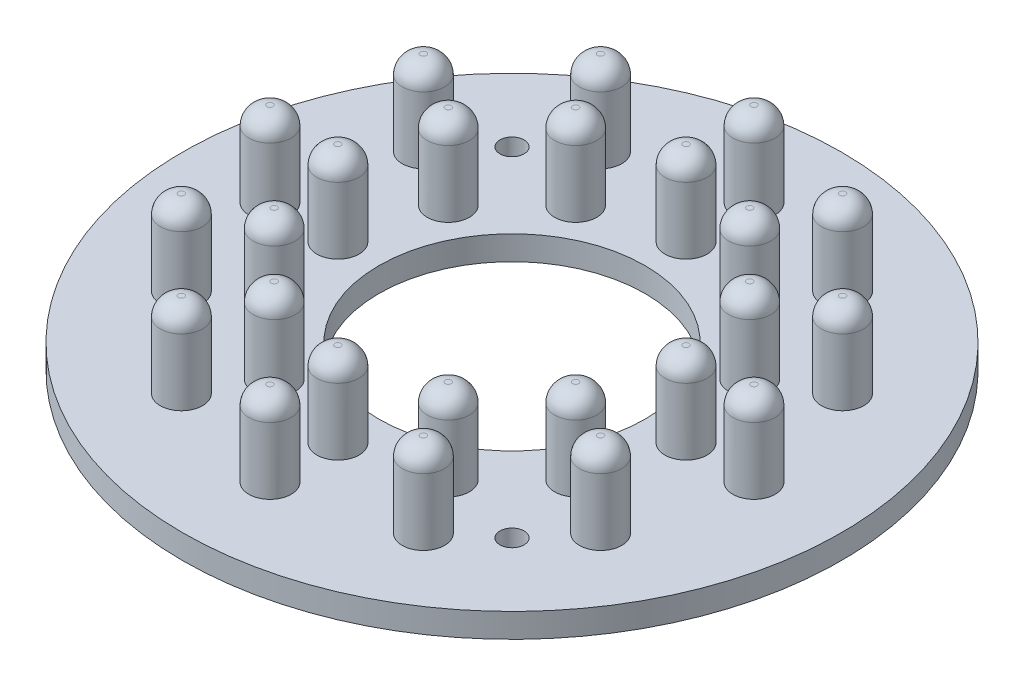
from build123d import *

# Parameters (mm, degrees)
SKETCH1_R                = 27.25
SKETCH1_R_2              = 11
BOSS_EXTRUDE1_DEPTH      = 2
SKETCH2_R                = 1.75
BOSS_EXTRUDE2_DEPTH      = 7
SKETCH3_R                = 1
CUT_EXTRUDE1_DEPTH       = 3
CIRPATTERN1_COUNT        = 4
FILLET1_R                = 1.5
CIRPATTERN2_COUNT        = 12
FILLET1_OF_CIRPATTERN2_R = 1.5


with BuildPart() as part:
    # Sketch1 → Boss-Extrude1 (new body)
    with BuildSketch(Plane(origin=(0, 0, 0), x_dir=(1, 0, 0), z_dir=(0, 1, 0))):
        Circle(SKETCH1_R)
        Circle(SKETCH1_R_2, mode=Mode.SUBTRACT)
    extrude(amount=BOSS_EXTRUDE1_DEPTH)

    # Sketch2 → Boss-Extrude2 (add)
    with BuildSketch(Plane(origin=(0, 2, 0), x_dir=(1, 0, 0), z_dir=(0, 1, 0))):
        with Locations((0, 14.391307105)):
            Circle(SKETCH2_R)
        with Locations((0, 20.010324854)):
            Circle(SKETCH2_R)
    boss_extrude2 = extrude(amount=BOSS_EXTRUDE2_DEPTH)

    # Sketch3 → Cut-Extrude1 (cut, through all)
    with BuildSketch(Plane(origin=(0, 2, 0), x_dir=(1, 0, 0), z_dir=(0, 1, 0))):
        with Locations((-14.000714267, 14.000714267)):
            Circle(SKETCH3_R)
    cut_extrude1 = extrude(amount=-CUT_EXTRUDE1_DEPTH, mode=Mode.SUBTRACT)

    # CirPattern1: Cut-Extrude1 ×4 about axis
    cirpattern1_axis = Axis((0, 0, 0), (0, 1, 0))
    for i in range(1, CIRPATTERN1_COUNT):
        add(cut_extrude1.rotate(cirpattern1_axis, i * 360 / CIRPATTERN1_COUNT), mode=Mode.SUBTRACT)

    # Fillet1
    fillet1_edges = [part.edges().sort_by_distance(p)[0] for p in [
        (-1.75, 9, -14.391307105),
        (-1.75, 9, -20.010324854),
    ]]
    fillet(fillet1_edges, radius=FILLET1_R)

    # CirPattern2: Boss-Extrude2 ×12 about axis
    cirpattern2_axis = Axis((0, 0, 0), (0, 1, 0))
    for i in range(1, CIRPATTERN2_COUNT):
        add(boss_extrude2.rotate(cirpattern2_axis, i * 360 / CIRPATTERN2_COUNT))

    # Fillet1 of CirPattern2
    fillet1_of_cirpattern2_edges = [part.edges().sort_by_distance(p)[0] for p in [
        (-8.711198009, 9, -11.588237546),
        (-11.520706884, 9, -16.454449662),
        (-13.338237546, 9, -5.680109096),
        (-18.204449662, 9, -8.48961797),
        (-14.391307105, 9, 1.75),
        (-20.010324854, 9, 1.75),
        (-11.588237546, 9, 8.711198009),
        (-16.454449662, 9, 11.520706884),
        (-5.680109096, 9, 13.338237546),
        (-8.48961797, 9, 18.204449662),
        (1.75, 9, 14.391307105),
        (1.75, 9, 20.010324854),
        (8.711198009, 9, 11.588237546),
        (11.520706884, 9, 16.454449662),
        (13.338237546, 9, 5.680109096),
        (18.204449662, 9, 8.48961797),
        (14.391307105, 9, -1.75),
        (20.010324854, 9, -1.75),
        (11.588237546, 9, -8.711198009),
        (16.454449662, 9, -11.520706884),
        (5.680109096, 9, -13.338237546),
        (8.48961797, 9, -18.204449662),
    ]]
    fillet(fillet1_of_cirpattern2_edges, radius=FILLET1_OF_CIRPATTERN2_R)


solid = part.part
